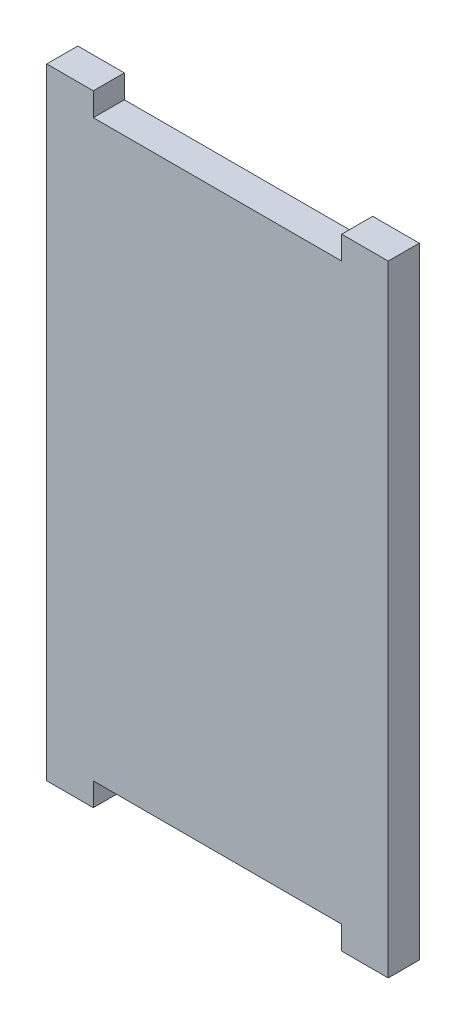
from build123d import *

# Parameters (mm, degrees)
SKETCH_4_W          = 44
SKETCH_4_H          = 80
EXTRUDE_2_DEPTH     = 4
SKETCH_6_W          = 32
SKETCH_6_H          = 3
CUT_EXTRUDE_1_DEPTH = 5


with BuildPart() as part:
    # 스케치4 → 보스-돌출2 (new body)
    with BuildSketch(Plane.XY):
        with Locations((22, 40)):
            Rectangle(SKETCH_4_W, SKETCH_4_H)
    extrude(amount=EXTRUDE_2_DEPTH)

    # 스케치6 → 컷-돌출1 (cut, through all)
    with BuildSketch(Plane.XY.offset(4)):
        with Locations((22, 78.5)):
            Rectangle(SKETCH_6_W, SKETCH_6_H)
        with Locations((22, 1.5)):
            Rectangle(SKETCH_6_W, SKETCH_6_H)
    extrude(amount=-CUT_EXTRUDE_1_DEPTH, mode=Mode.SUBTRACT)


solid = part.part
